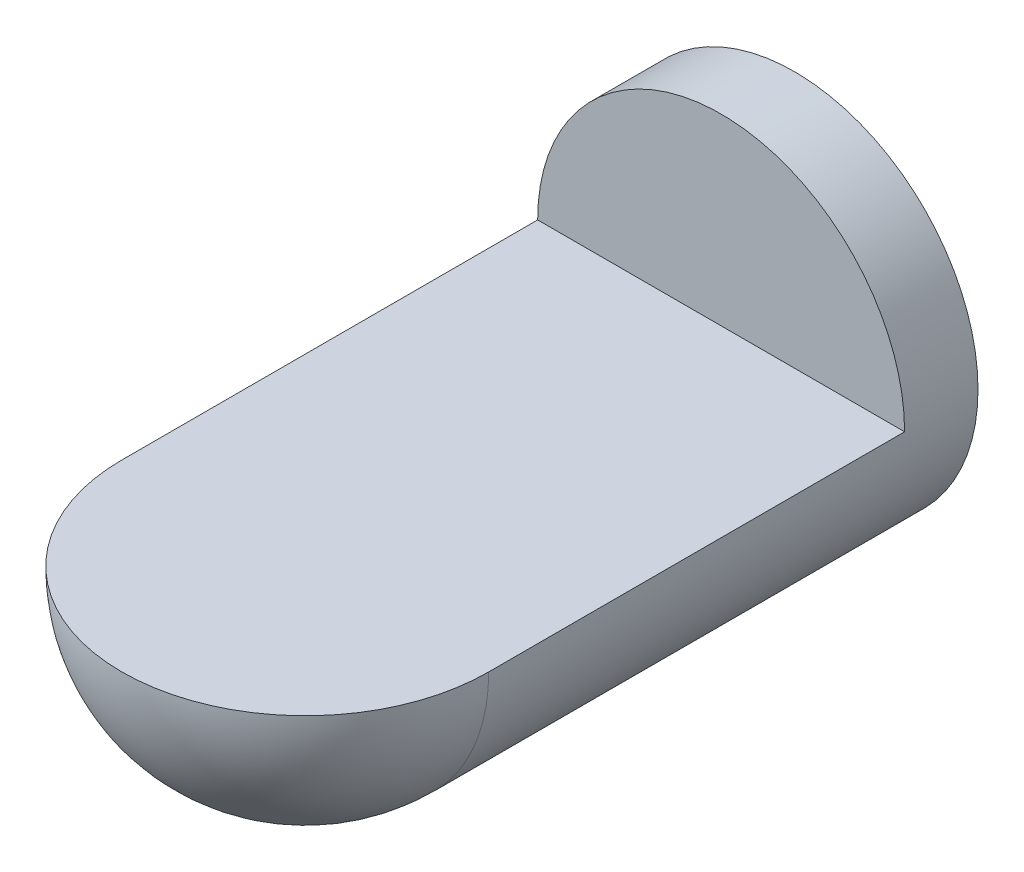
from build123d import *

# Parameters (mm, degrees)
CUT_EXTRUDE1_DEPTH      = 227.384628453
CUT_EXTRUDE1_DEPTH_BACK = 227.384628453


with BuildPart() as part:
    # Sketch1 → Revolve1 (revolve)
    with BuildSketch(Plane(origin=(0, 0, 0), x_dir=(0, 0, -1), z_dir=(1, 0, 0))):
        with BuildLine():
            Line((200, 0), (-75, 0))
            ThreePointArc((-75, 0), (-53.033008589, 53.033008589), (0, 75))
            Line((0, 75), (200, 75))
            Line((200, 75), (200, 0))
        make_face()
    revolve(axis=Axis((0, 0, 146.909145291), (0, 0, -1)))

    # Sketch2 → Cut-Extrude1 (cut, two sides: drawn at the far end of the back side and taken through both)
    with BuildSketch(Plane(origin=(0, 0, 0), x_dir=(0, 0, -1), z_dir=(1, 0, 0)).offset(-CUT_EXTRUDE1_DEPTH_BACK)):
        with BuildLine():
            Line((170, 0), (170, 75))
            Line((170, 75), (0, 75))
            ThreePointArc((0, 75), (-53.033008589, 53.033008589), (-75, 0))
            Line((-75, 0), (170, 0))
        make_face()
    extrude(amount=CUT_EXTRUDE1_DEPTH + CUT_EXTRUDE1_DEPTH_BACK, mode=Mode.SUBTRACT)


solid = part.part
